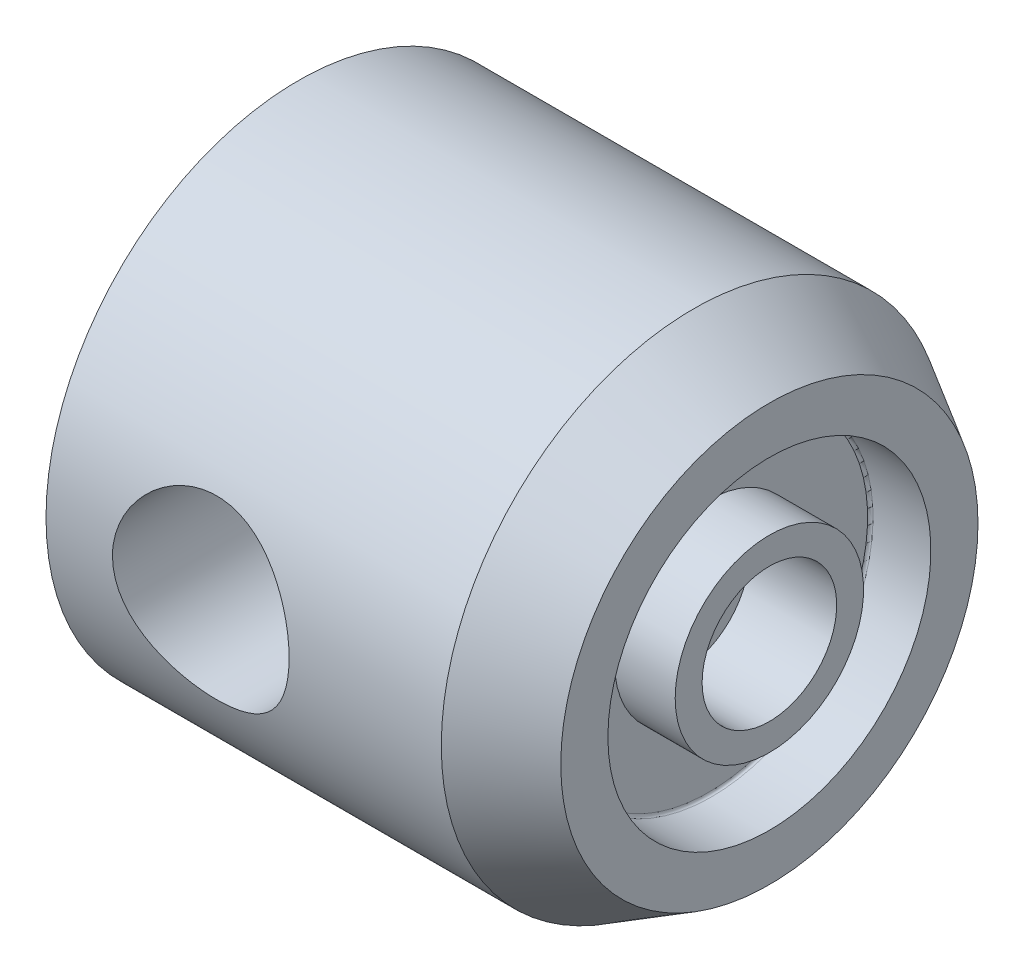
from build123d import *

# Parameters (mm, degrees)
SKETCH4_R          = 13.125
CUT_EXTRUDE1_DEPTH = 45
FILLET1_R          = 0.4


with BuildPart() as part:
    # Sketch1 → Base-Revolve (revolve)
    with BuildSketch(Plane.XY, mode=Mode.PRIVATE) as base_revolve_sk:
        Polygon((-23, 0), (-23, 37.5), (35.741669751, 37.5), (47, 31), (47, 24), (38, 24), (38, 14), (47, 14), (47, 10), (34, 10), (34, 6), (25, 6), (21.535898385, 0), align=None)
    revolve(base_revolve_sk.sketch.rotate(Axis((-65.592135762, 0, 0), (1, 0, 0)), 90), axis=Axis((-65.592135762, 0, 0), (1, 0, 0)))

    # Sketch2 → Cut-Revolve1 (revolve, cut)
    with BuildSketch(Plane.XY, mode=Mode.PRIVATE) as cut_revolve1_sk:
        Polygon((-23, 36), (-21.5, 36), (-21.5, 31.65), (39, 31.65), (43.416729559, 24), (-23, 24), align=None)
    revolve(cut_revolve1_sk.sketch.rotate(Axis((-29.427152318, 24, 0), (1, 0, 0)), 90), axis=Axis((-29.427152318, 24, 0), (1, 0, 0)), mode=Mode.SUBTRACT)

    # Sketch3 → Cut-Revolve2 (revolve, cut)
    with BuildSketch(Plane.XY, mode=Mode.PRIVATE) as cut_revolve2_sk:
        Polygon((-23, -36), (-21.5, -36), (-21.5, -31.65), (29, -31.65), (33.416729559, -24), (-23, -24), align=None)
    revolve(cut_revolve2_sk.sketch.rotate(Axis((-27.440397351, -24, 0), (1, 0, 0)), 270), axis=Axis((-27.440397351, -24, 0), (1, 0, 0)), mode=Mode.SUBTRACT)

    # Sketch4 → Cut-Extrude1 (cut, symmetric)
    with BuildSketch(Plane.XY):
        Circle(SKETCH4_R)
    extrude(amount=CUT_EXTRUDE1_DEPTH, both=True, mode=Mode.SUBTRACT)

    # Sketch5 → Cut-Revolve3 (revolve, cut)
    with BuildSketch(Plane(origin=(24, 0, 0), x_dir=(0, 0, -1), z_dir=(1, 0, 0)), mode=Mode.PRIVATE) as cut_revolve3_sk:
        Polygon((16.059493946, -34.439695907), (25.122571817, -30.21351329), (24.277335293, -28.400897716), (20.561473366, -30.133632589), (2.811506373, 7.931294466), (-3.975302297, 8.525063287), align=None)
    revolve(cut_revolve3_sk.sketch.rotate(Axis((24, 0, 0), (0, -0.9063077870366493, -0.422618261740701)), 180), axis=Axis((24, 0, 0), (0, -0.9063077870366493, -0.422618261740701)), mode=Mode.SUBTRACT)

    # Fillet1
    fillet1_edges = [part.edges().sort_by_distance(p)[0] for p in [
        (38, -19.458330429, -14.048963553),
    ]]
    fillet(fillet1_edges, radius=FILLET1_R)


solid = part.part
